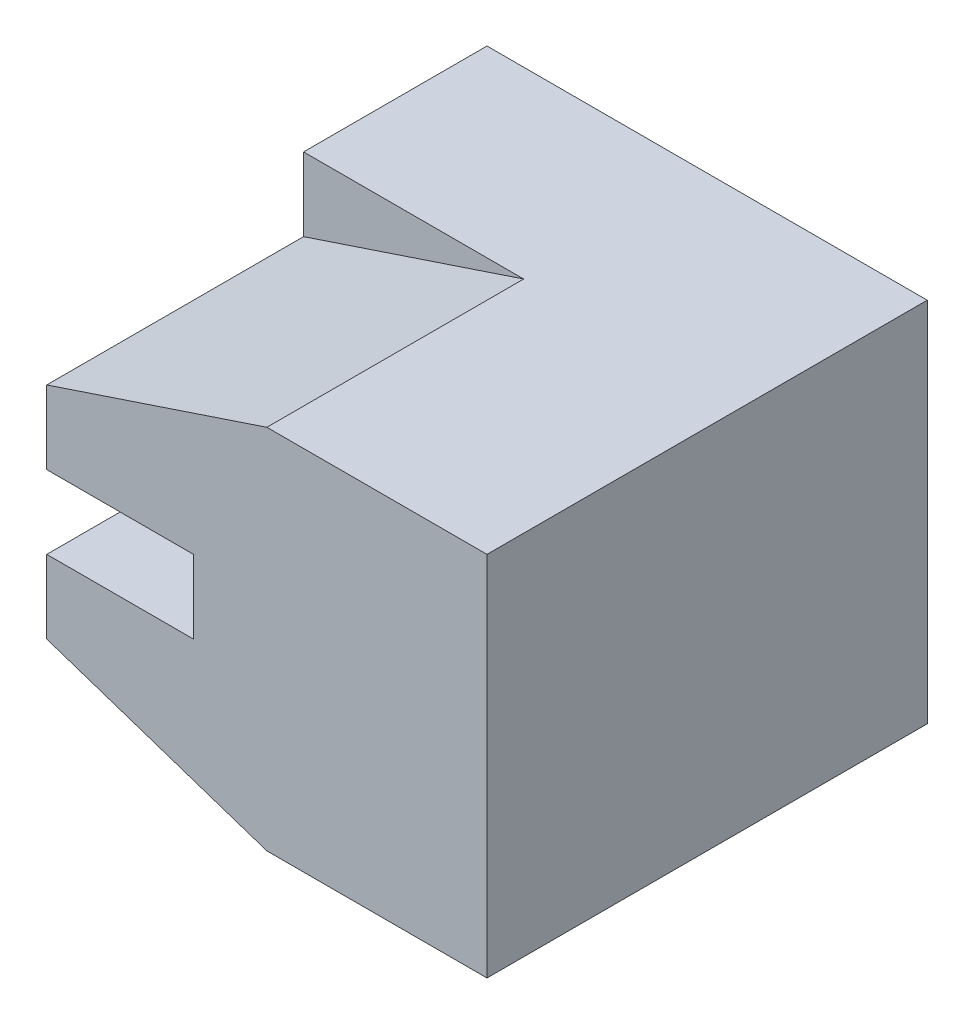
from build123d import *

# Parameters (mm, degrees)
SKETCH1_W           = 6
SKETCH1_H           = 6
BOSS_EXTRUDE1_DEPTH = 5
SKETCH2_W           = 3.5
SKETCH2_H           = 1
CUT_EXTRUDE1_DEPTH  = 2
CUT_EXTRUDE2_DEPTH  = 3.5


with BuildPart() as part:
    # Sketch1 → Boss-Extrude1 (new body)
    with BuildSketch(Plane(origin=(0, 0, 0), x_dir=(1, 0, 0), z_dir=(0, 1, 0))):
        Rectangle(SKETCH1_W, SKETCH1_H)
    extrude(amount=BOSS_EXTRUDE1_DEPTH)

    # Sketch2 → Cut-Extrude1 (cut)
    with BuildSketch(Plane.ZY.offset(3)):
        with Locations((1.25, 2.5)):
            Rectangle(SKETCH2_W, SKETCH2_H)
    extrude(amount=-CUT_EXTRUDE1_DEPTH, mode=Mode.SUBTRACT)

    # Sketch3 → Cut-Extrude2 (cut)
    with BuildSketch(Plane.XY.offset(3)):
        Polygon((-3, 5), (-3, 4), (0, 5), align=None)
        Polygon((-3, 0), (0, 0), (-3, 1), align=None)
    extrude(amount=-CUT_EXTRUDE2_DEPTH, mode=Mode.SUBTRACT)


solid = part.part
